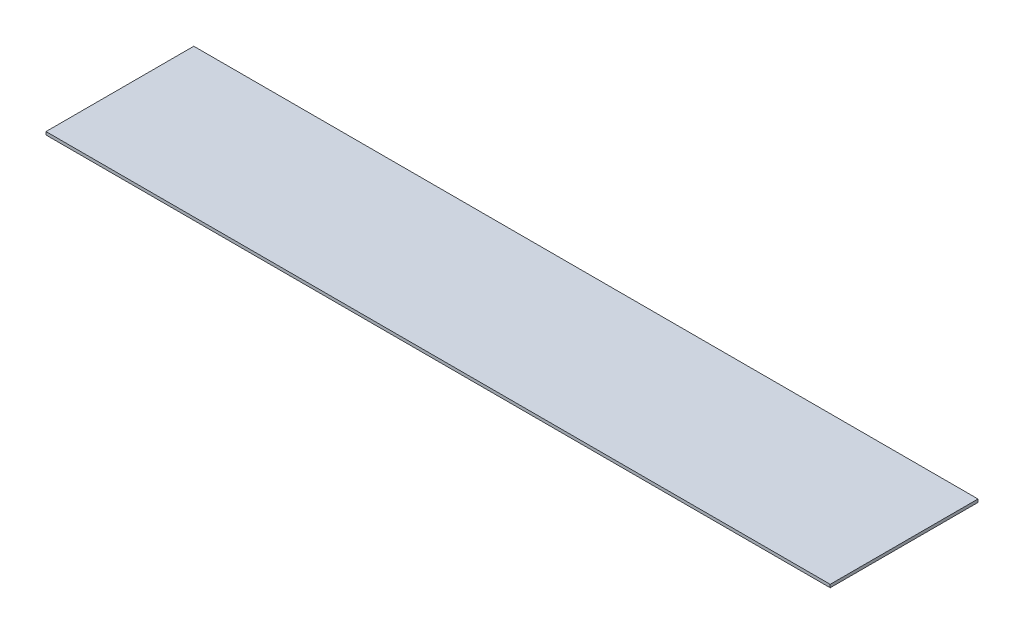
from build123d import *

# Parameters (mm, degrees)
SKETCH1_W           = 260
SKETCH1_H           = 49
BOSS_EXTRUDE1_DEPTH = 1


with BuildPart() as part:
    # Sketch1 → Boss-Extrude1 (new body)
    with BuildSketch(Plane(origin=(0, 0, 0), x_dir=(1, 0, 0), z_dir=(0, 1, 0))):
        with Locations((23.684210526, 26.289473684)):
            Rectangle(SKETCH1_W, SKETCH1_H)
    extrude(amount=BOSS_EXTRUDE1_DEPTH)


solid = part.part
